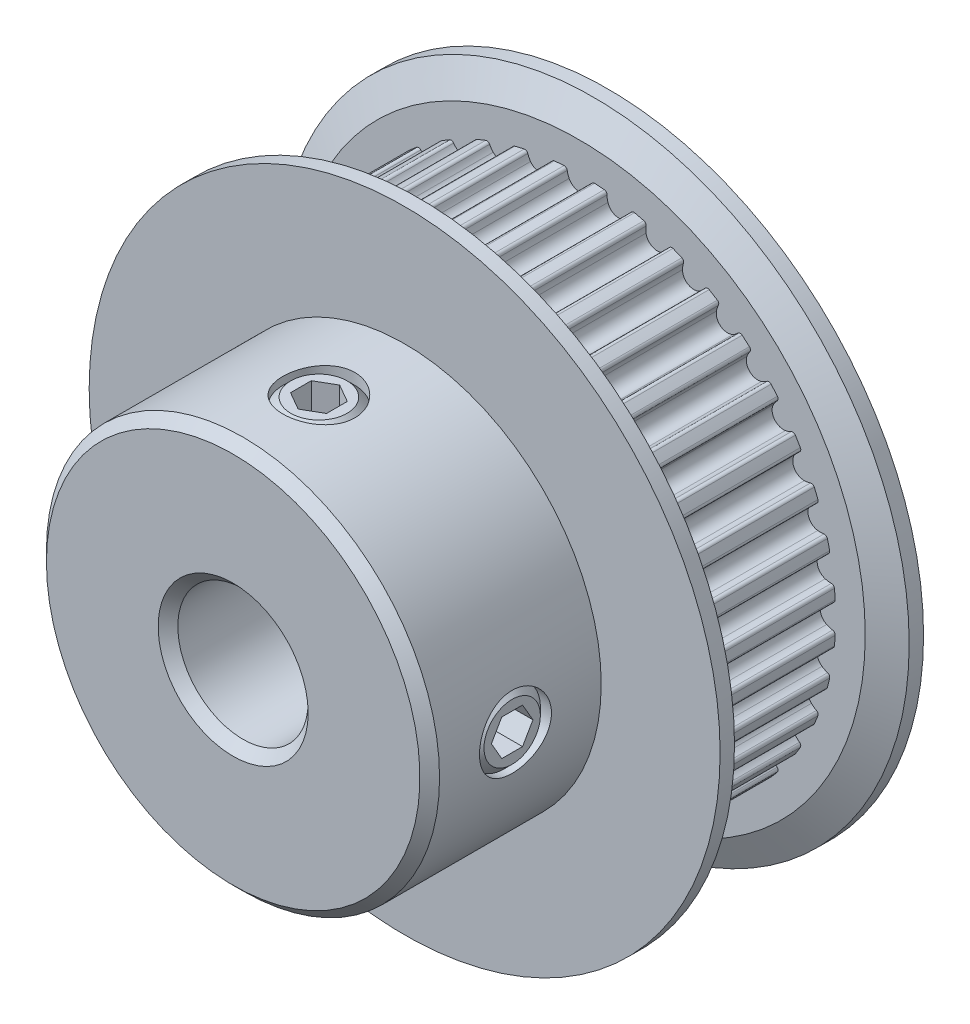
from build123d import *

# Parameters (mm, degrees)
CUT_EXTRUDE1_START = -0.6213
CUT_EXTRUDE1_DEPTH = 7.11
CIRPATTERN1_COUNT  = 40
SKETCH4_R          = 1.7526
CUT_EXTRUDE2_DEPTH = 24.572654023
CUT_EXTRUDE3_DEPTH = 1.31445
CIRPATTERN2_COUNT  = 2
CIRPATTERN2_ANGLE  = 90
CHAMFER1_SIZE      = 0.47875


with BuildPart() as part:
    # Sketch2 → Revolve1 (revolve)
    with BuildSketch(Plane(origin=(0, 0, 0), x_dir=(0, 0, -1), z_dir=(1, 0, 0)), mode=Mode.PRIVATE) as revolve1_sk:
        Polygon((-9.1313, 3.175), (9.1313, 3.175), (9.1313, 15.367), (8.4313, 15.367), (7.7313, 13.9255), (7.7313, 12.484), (0.6213, 12.484), (0.6213, 13.9255), (-0.0787, 15.367), (-0.7787, 15.367), (-0.7787, 9.575), (-9.1313, 9.575), align=None)
    revolve(revolve1_sk.sketch.rotate(Axis((0, 0, 9.1313), (0, 0, -1)), 90), axis=Axis((0, 0, 9.1313), (0, 0, -1)))

    # Sketch3 → Cut-Extrude1 (cut)
    with BuildSketch(Plane.XY.offset(CUT_EXTRUDE1_START)):
        with BuildLine():
            Line((2.435352616, 15.367), (-2.435352616, 15.367))
            Line((-2.435352616, 15.367), (-1.954069811, 12.330120323))
            ThreePointArc((-1.954069811, 12.330120323), (-1.351647708, 12.410612574), (-0.746021972, 12.461689581))
            ThreePointArc((-0.746021972, 12.461689581), (-0.642690496, 12.42855409), (-0.588746291, 12.334397956))
            ThreePointArc((-0.588746291, 12.334397956), (-0.554778707, 12.186682627), (-0.498876404, 12.045797753))
            ThreePointArc((-0.498876404, 12.045797753), (0, 11.734), (0.498876404, 12.045797753))
            ThreePointArc((0.498876404, 12.045797753), (0.554778707, 12.186682627), (0.588746291, 12.334397956))
            ThreePointArc((0.588746291, 12.334397956), (0.642690496, 12.42855409), (0.746021972, 12.461689581))
            ThreePointArc((0.746021972, 12.461689581), (1.351647708, 12.410612574), (1.954069811, 12.330120323))
            Line((1.954069811, 12.330120323), (2.435352616, 15.367))
        make_face()
    cut_extrude1 = extrude(amount=-CUT_EXTRUDE1_DEPTH, mode=Mode.SUBTRACT)

    # CirPattern1: Cut-Extrude1 ×40 about axis
    cirpattern1_axis = Axis((0, 0, 0), (0, 0, 1))
    for i in range(1, CIRPATTERN1_COUNT):
        add(cut_extrude1.rotate(cirpattern1_axis, i * 360 / CIRPATTERN1_COUNT), mode=Mode.SUBTRACT)

    # Sketch4 → Cut-Extrude2 (cut, through all)
    with BuildSketch(Plane(origin=(0, 0, 0), x_dir=(0, -1, 0), z_dir=(1, 0, 0))):
        with Locations(Location((0, -4.955, 0), (0, 0, 270.000000003))):
            Circle(SKETCH4_R)
    cut_extrude2 = extrude(amount=CUT_EXTRUDE2_DEPTH, mode=Mode.SUBTRACT)

    # Sketch5 → Revolve2 (revolve)
    with BuildSketch(Plane.XY.offset(4.955), mode=Mode.PRIVATE) as revolve2_sk:
        Polygon((3.175, -1.3716), (3.175, 0), (9.413236332, 0), (9.413236332, -1.3716), (9.032236332, -1.7526), (3.556, -1.7526), align=None)
    revolve2 = revolve(revolve2_sk.sketch.rotate(Axis((3.175, 0, 4.955), (1, 0, 0)), 270), axis=Axis((3.175, 0, 4.955), (1, 0, 0)))

    # Sketch6 → Cut-Extrude3 (cut)
    with BuildSketch(Plane(origin=(9.413236332, 5.384140679, 0), x_dir=(0, -1, 0), z_dir=(-1, 0, 0))):
        Polygon((5.384140679, 5.966864082), (4.507840679, 5.460932041), (4.507840679, 4.449067959), (5.384140679, 3.943135918), (6.260440679, 4.449067959), (6.260440679, 5.460932041), align=None)
    cut_extrude3 = extrude(amount=CUT_EXTRUDE3_DEPTH, mode=Mode.SUBTRACT)

    # CirPattern2: Cut-Extrude2, Revolve2, Cut-Extrude3 ×2 about axis
    cirpattern2_axis = Axis((0, 0, 0), (0, 0, 1))
    add([cut_extrude2.rotate(cirpattern2_axis, i * CIRPATTERN2_ANGLE / (CIRPATTERN2_COUNT - 1)) for i in range(1, CIRPATTERN2_COUNT)], mode=Mode.SUBTRACT)
    add([revolve2.rotate(cirpattern2_axis, i * CIRPATTERN2_ANGLE / (CIRPATTERN2_COUNT - 1)) for i in range(1, CIRPATTERN2_COUNT)])
    add([cut_extrude3.rotate(cirpattern2_axis, i * CIRPATTERN2_ANGLE / (CIRPATTERN2_COUNT - 1)) for i in range(1, CIRPATTERN2_COUNT)], mode=Mode.SUBTRACT)

    # Chamfer1
    chamfer1_edges = [part.edges().sort_by_distance(p)[0] for p in [
        (-9.575, 0, 9.1313),
        (-3.175, 0, 9.1313),
    ]]
    chamfer(chamfer1_edges, length=CHAMFER1_SIZE)


solid = part.part
